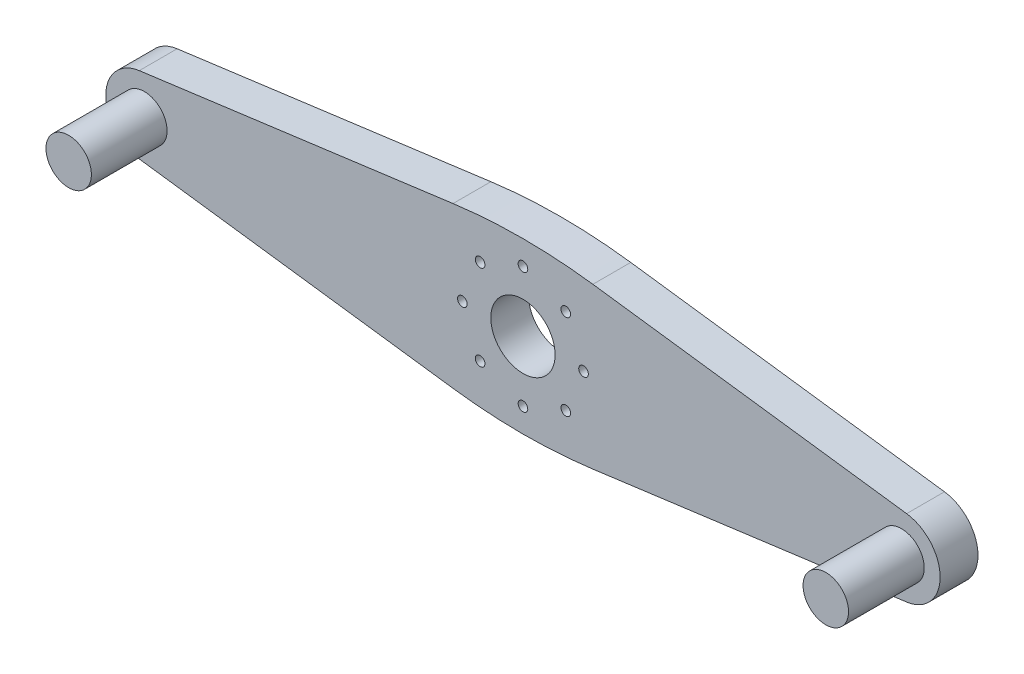
from build123d import *

# Parameters (mm, degrees)
SZKIC1_R                    = 4.25
SZKIC1_R_2                  = 0.635
SZKIC1_R_3                  = 3
DODANIE_WYCI_GNI_CIE1_DEPTH = 5
SZKIC1_2_R                  = 3
DODANIE_WYCI_GNI_CIE2_DEPTH = 15


with BuildPart() as part:
    # Szkic1 → Dodanie-wyci_gni_cie1 (new body)
    with BuildSketch(Plane.XY):
        with BuildLine():
            Line((-50.67287635, 5.055665151), (-9.235111676, 10.570763761))
            ThreePointArc((-9.235111676, 10.570763761), (0, 11.182632843), (9.235111676, 10.570763761))
            Line((9.235111676, 10.570763761), (50.67287635, 5.055665151))
            ThreePointArc((50.67287635, 5.055665151), (55.100246338, 0), (50.67287635, -5.055665151))
            Line((50.67287635, -5.055665151), (9.235111676, -10.570763761))
            ThreePointArc((9.235111676, -10.570763761), (0, -11.182632843), (-9.235111676, -10.570763761))
            Line((-9.235111676, -10.570763761), (-50.67287635, -5.055665151))
            ThreePointArc((-50.67287635, -5.055665151), (-55.100246338, 0), (-50.67287635, 5.055665151))
        make_face()
        Circle(SZKIC1_R, mode=Mode.SUBTRACT)
        with Locations((-5.656854249, 5.656854249)):
            Circle(SZKIC1_R_2, mode=Mode.SUBTRACT)
        with Locations((-8, 0)):
            Circle(SZKIC1_R_2, mode=Mode.SUBTRACT)
        with Locations((0, 8)):
            Circle(SZKIC1_R_2, mode=Mode.SUBTRACT)
        with Locations((5.656854249, 5.656854249)):
            Circle(SZKIC1_R_2, mode=Mode.SUBTRACT)
        with Locations((-50, 0)):
            Circle(SZKIC1_R_3, mode=Mode.SUBTRACT)
        with Locations((50, 0)):
            Circle(SZKIC1_R_3, mode=Mode.SUBTRACT)
        with Locations((8, 0)):
            Circle(SZKIC1_R_2, mode=Mode.SUBTRACT)
        with Locations((5.656854249, -5.656854249)):
            Circle(SZKIC1_R_2, mode=Mode.SUBTRACT)
        with Locations((0, -8)):
            Circle(SZKIC1_R_2, mode=Mode.SUBTRACT)
        with Locations((-5.656854249, -5.656854249)):
            Circle(SZKIC1_R_2, mode=Mode.SUBTRACT)
    extrude(amount=DODANIE_WYCI_GNI_CIE1_DEPTH)

    # Szkic1_2 → Dodanie-wyci_gni_cie2 (add)
    with BuildSketch(Plane.XY):
        with Locations((-50, 0)):
            Circle(SZKIC1_2_R)
        with Locations((50, 0)):
            Circle(SZKIC1_2_R)
    extrude(amount=DODANIE_WYCI_GNI_CIE2_DEPTH)


solid = part.part
